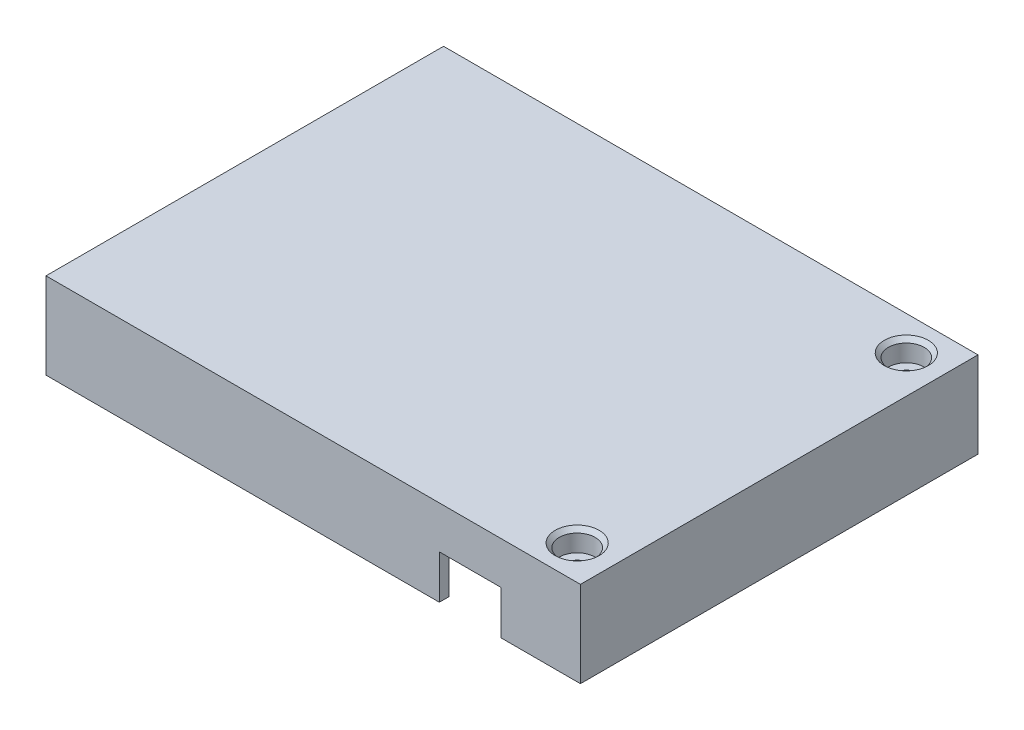
from build123d import *

# Parameters (mm, degrees)
SKETCH1_W                      = 82
SKETCH1_H                      = 61
BOSS_EXTRUDE1_DEPTH            = 13.2
SHELL2_T                       = -1.5
SKETCH2_W                      = 7.75
SKETCH2_H                      = 7.75
BOSS_EXTRUDE2_DEPTH            = 10
BOSS_EXTRUDE3_DEPTH            = 1.7
MIRROR2_COPY_1_SKETCH_W        = 7.75
MIRROR2_COPY_1_SKETCH_H        = 7.75
MIRROR2_COPY_1_DEPTH           = 10
CUT_EXTRUDE1_REACH             = 76.674
SKETCH9_W                      = 9.5
SKETCH9_H                      = 6.7
CUT_EXTRUDE1_DIRECTION_2_DEPTH = 75.674225808


with BuildPart() as part:
    # Sketch1 → Boss-Extrude1 (new body)
    with BuildSketch(Plane(origin=(0, 0, 0), x_dir=(1, 0, 0), z_dir=(0, 1, 0))):
        Rectangle(SKETCH1_W, SKETCH1_H)
    extrude(amount=BOSS_EXTRUDE1_DEPTH)

    # Shell2
    shell2_openings = [part.faces().sort_by_distance(p)[0] for p in [
        (0, 0, 0),
    ]]
    offset(amount=SHELL2_T, openings=shell2_openings, kind=Kind.INTERSECTION)

    # Sketch2 → Boss-Extrude2 (add)
    with BuildSketch(Plane.XZ.offset(-11.7)):
        with Locations((35.625, 25.125)):
            Rectangle(SKETCH2_W, SKETCH2_H)
    boss_extrude2 = extrude(amount=BOSS_EXTRUDE2_DEPTH)

    # Mirror1: Boss-Extrude2 across plane
    add(boss_extrude2.mirror(Plane(origin=(0, 0, 0), x_dir=(0, 0, 1), z_dir=(1, 0, 0))))

    # Sketch6 → CBORE for M5 Hex Head Bolt1 (revolve, cut)
    with BuildSketch(Plane(origin=(35.25, 13.2, 25.25), x_dir=(0, 0, 1), z_dir=(1, 0, 0))):
        Polygon((0, 0), (0, 13.2), (1.375, 13.2), (1.375, 3.25), (2.75, 3.25), (2.75, 0.625), (3.375, 0), align=None)
    cbore_for_m5_hex_head_bolt1 = revolve(axis=Axis((35.25, 19.55, 25.25), (0, -1, 0)), mode=Mode.SUBTRACT)

    # Sketch8 → Boss-Extrude3 (add)
    with BuildSketch(Plane.XZ.offset(-1.7)):
        with BuildLine():
            Line((-36.35, 29), (-33.15, 29))
            ThreePointArc((-33.15, 29), (-34.75, 27.4), (-36.35, 29))
        make_face()
    boss_extrude3 = extrude(amount=BOSS_EXTRUDE3_DEPTH)

    # Mirror2: Boss-Extrude2, CBORE for M5 Hex Head Bolt1, Boss-Extrude3 across plane
    add(boss_extrude2.mirror(Plane.XY))
    add(cbore_for_m5_hex_head_bolt1.mirror(Plane.XY), mode=Mode.SUBTRACT)
    add(boss_extrude3.mirror(Plane.XY))

    # Mirror2 copy 1 sketch → Mirror2 copy 1 (add)
    with BuildSketch(Plane(origin=(0, 11.7, 0), x_dir=(-1, 0, 0), z_dir=(0, -1, 0))):
        with Locations((35.625, 25.125)):
            Rectangle(MIRROR2_COPY_1_SKETCH_W, MIRROR2_COPY_1_SKETCH_H)
    extrude(amount=MIRROR2_COPY_1_DEPTH)

    # Sketch9 → Cut-Extrude1 (cut, up to next)
    with BuildSketch(Plane.XY.offset(30.5), mode=Mode.PRIVATE) as cut_extrude1_sk1:
        with Locations((24.1, 3.35)):
            Rectangle(SKETCH9_W, SKETCH9_H)
    cut_extrude1_tool1 = extrude(cut_extrude1_sk1.sketch, amount=-CUT_EXTRUDE1_REACH, mode=Mode.PRIVATE) & part.part
    add(cut_extrude1_tool1.solids().sort_by_distance((24.1, 3.35, 30.5))[0], mode=Mode.SUBTRACT)

    # Sketch9 → Cut-Extrude1 direction 2 (cut)
    with BuildSketch(Plane.XY.offset(30.5)):
        with Locations((24.1, 3.35)):
            Rectangle(SKETCH9_W, SKETCH9_H)
    extrude(amount=CUT_EXTRUDE1_DIRECTION_2_DEPTH, mode=Mode.SUBTRACT)


solid = part.part
